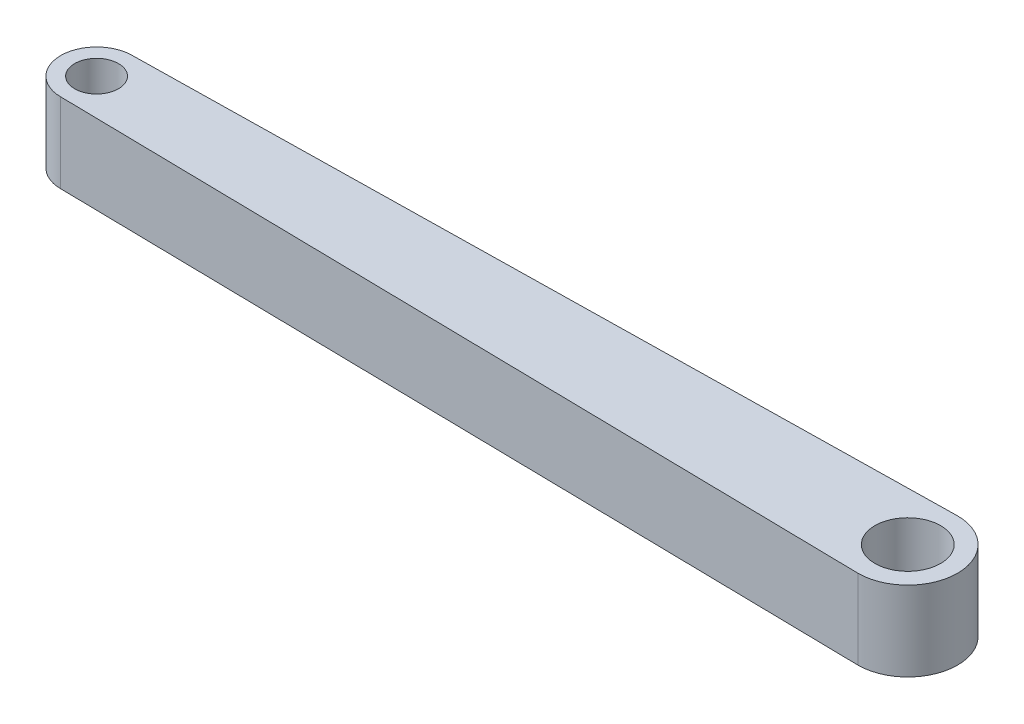
from build123d import *

# Parameters (mm, degrees)
SKETCH1_R           = 0.55
SKETCH1_R_2         = 0.825
BOSS_EXTRUDE1_DEPTH = 2


with BuildPart() as part:
    # Sketch1 → Boss-Extrude1 (new body)
    with BuildSketch(Plane(origin=(0, 0, 0), x_dir=(1, 0, 0), z_dir=(0, 1, 0))):
        with BuildLine():
            Line((10.14707841, 1.249262877), (-10.19, 0.9))
            ThreePointArc((-10.19, 0.9), (-11.09, 0), (-10.19, -0.9))
            Line((-10.19, -0.9), (10.14707841, -1.249262877))
            Line((10.14707841, -1.249262877), (10.19, -1.25))
            ThreePointArc((10.19, -1.25), (11.44, 0), (10.19, 1.25))
            Line((10.19, 1.25), (10.14707841, 1.249262877))
        make_face()
        with Locations((-10.19, 0)):
            Circle(SKETCH1_R, mode=Mode.SUBTRACT)
        with Locations((10.19, 0)):
            Circle(SKETCH1_R_2, mode=Mode.SUBTRACT)
    extrude(amount=BOSS_EXTRUDE1_DEPTH)


solid = part.part
